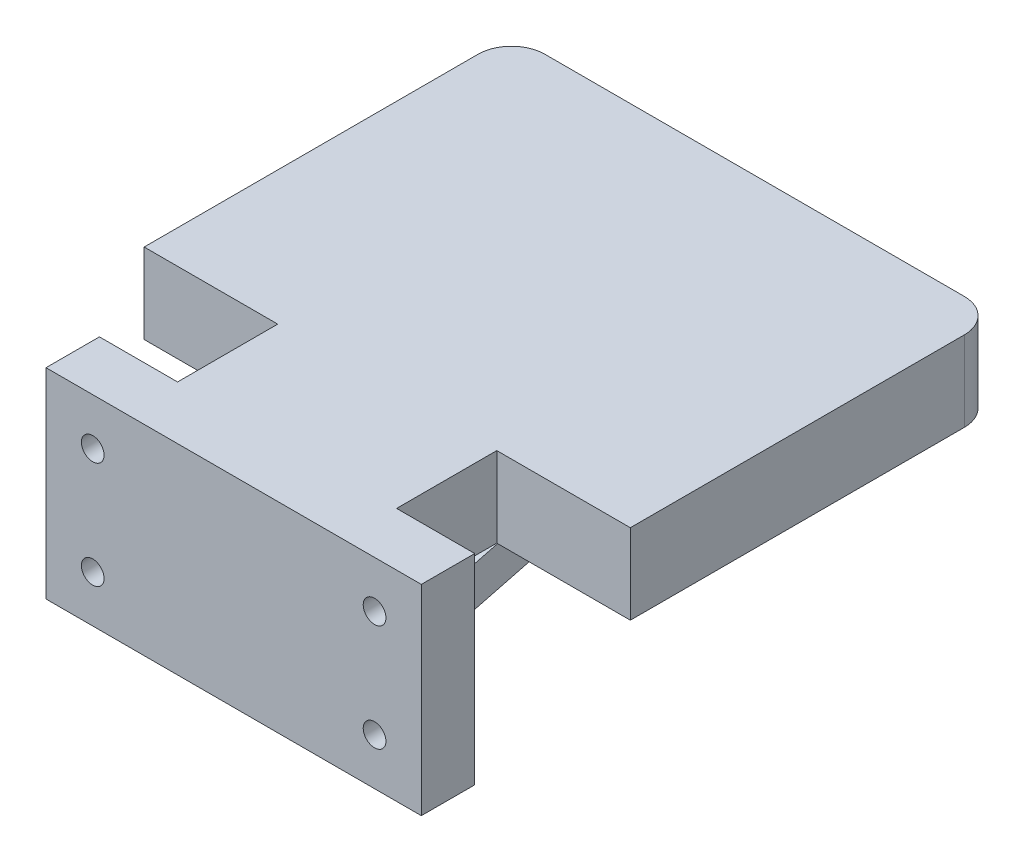
from build123d import *

# Parameters (mm, degrees)
SKETCH1_W                      = 56.2
SKETCH1_H                      = 30
BOSS_EXTRUDE1_DEPTH            = 5
SKETCH3_W                      = 56.2
SKETCH3_H                      = 30
BOSS_EXTRUDE2_DEPTH            = 3
SKETCH4_R                      = 1.7
CUT_EXTRUDE2_DEPTH             = 8
BOSS_EXTRUDE3_DEPTH            = 12
BOSS_EXTRUDE4_DEPTH            = 10
BOSS_EXTRUDE4_DEPTH_BACK       = 10
CUT_EXTRUDE3_REACH             = 38.4
CUT_EXTRUDE3_DIRECTION_2_REACH = 38.4
SKETCH8_R                      = 2.6
CUT_EXTRUDE4_DEPTH             = 4


with BuildPart() as part:
    # Sketch1 → Boss-Extrude1 (new body)
    with BuildSketch(Plane.XY):
        with Locations((28.1, -15)):
            Rectangle(SKETCH1_W, SKETCH1_H)
    extrude(amount=BOSS_EXTRUDE1_DEPTH)

    # Sketch3 → Boss-Extrude2 (add)
    with BuildSketch(Plane.XY.offset(5)):
        with Locations((28.1, -15)):
            Rectangle(SKETCH3_W, SKETCH3_H)
    extrude(amount=BOSS_EXTRUDE2_DEPTH)

    # Sketch4 → Cut-Extrude2 (cut)
    with BuildSketch(Plane(origin=(0, 0, 0), x_dir=(-1, 0, 0), z_dir=(0, 0, -1))):
        with Locations((-49.2, -7)):
            Circle(SKETCH4_R)
        with Locations((-7, -7)):
            Circle(SKETCH4_R)
        with Locations((-7, -23)):
            Circle(SKETCH4_R)
        with Locations((-49.2, -23)):
            Circle(SKETCH4_R)
    extrude(amount=-CUT_EXTRUDE2_DEPTH, mode=Mode.SUBTRACT)

    # Sketch5 → Boss-Extrude3 (add)
    with BuildSketch(Plane(origin=(0, 0, 0), x_dir=(1, 0, 0), z_dir=(0, 1, 0))):
        with BuildLine():
            Line((44.5, 0), (11.7, 0))
            Line((11.7, 0), (11.7, 15))
            Line((11.7, 15), (-8.3, 15))
            Line((-8.3, 15), (-8.3, 65))
            ThreePointArc((-8.3, 65), (-6.835533906, 68.535533906), (-3.3, 70))
            Line((-3.3, 70), (59.5, 70))
            ThreePointArc((59.5, 70), (63.035533906, 68.535533906), (64.5, 65))
            Line((64.5, 65), (64.5, 15))
            Line((64.5, 15), (44.5, 15))
            Line((44.5, 15), (44.5, 0))
        make_face()
    extrude(amount=-BOSS_EXTRUDE3_DEPTH)

    # Sketch6 → Boss-Extrude4 (add, two sides)
    with BuildSketch(Plane(origin=(28.1, 0, 0), x_dir=(0, 0, -1), z_dir=(1, 0, 0))) as boss_extrude4_sk:
        Polygon((0, -12), (0, -30), (70, -12), align=None)
    extrude(amount=BOSS_EXTRUDE4_DEPTH)
    extrude(boss_extrude4_sk.sketch, amount=-BOSS_EXTRUDE4_DEPTH_BACK)

    # Sketch7 → Cut-Extrude3 (cut, up to next)
    with BuildSketch(Plane(origin=(28.1, 0, 0), x_dir=(0, 0, -1), z_dir=(1, 0, 0)), mode=Mode.PRIVATE) as cut_extrude3_sk1:
        Polygon((8, -12), (8, -22), (46.888888889, -12), align=None)
    cut_extrude3_tool1 = extrude(cut_extrude3_sk1.sketch, amount=-CUT_EXTRUDE3_REACH, mode=Mode.PRIVATE) & part.part
    add(cut_extrude3_tool1.solids().sort_by_distance((28.1, -15.333333, -20.962963))[0], mode=Mode.SUBTRACT)

    # Sketch7 → Cut-Extrude3 direction 2 (cut, up to next)
    with BuildSketch(Plane(origin=(28.1, 0, 0), x_dir=(0, 0, -1), z_dir=(1, 0, 0)), mode=Mode.PRIVATE) as cut_extrude3_direction_2_sk1:
        Polygon((8, -12), (8, -22), (46.888888889, -12), align=None)
    cut_extrude3_direction_2_tool1 = extrude(cut_extrude3_direction_2_sk1.sketch, amount=CUT_EXTRUDE3_DIRECTION_2_REACH, mode=Mode.PRIVATE) & part.part
    add(cut_extrude3_direction_2_tool1.solids().sort_by_distance((28.1, -15.333333, -20.962963))[0], mode=Mode.SUBTRACT)

    # Sketch8 → Cut-Extrude4 (cut)
    with BuildSketch(Plane(origin=(0, 0, 0), x_dir=(-1, 0, 0), z_dir=(0, 0, -1))):
        with Locations((-49.2, -7)):
            Circle(SKETCH8_R)
        with Locations((-7, -7)):
            Circle(SKETCH8_R)
        with Locations((-7, -23)):
            Circle(SKETCH8_R)
        with Locations((-49.2, -23)):
            Circle(SKETCH8_R)
    extrude(amount=-CUT_EXTRUDE4_DEPTH, mode=Mode.SUBTRACT)


solid = part.part
